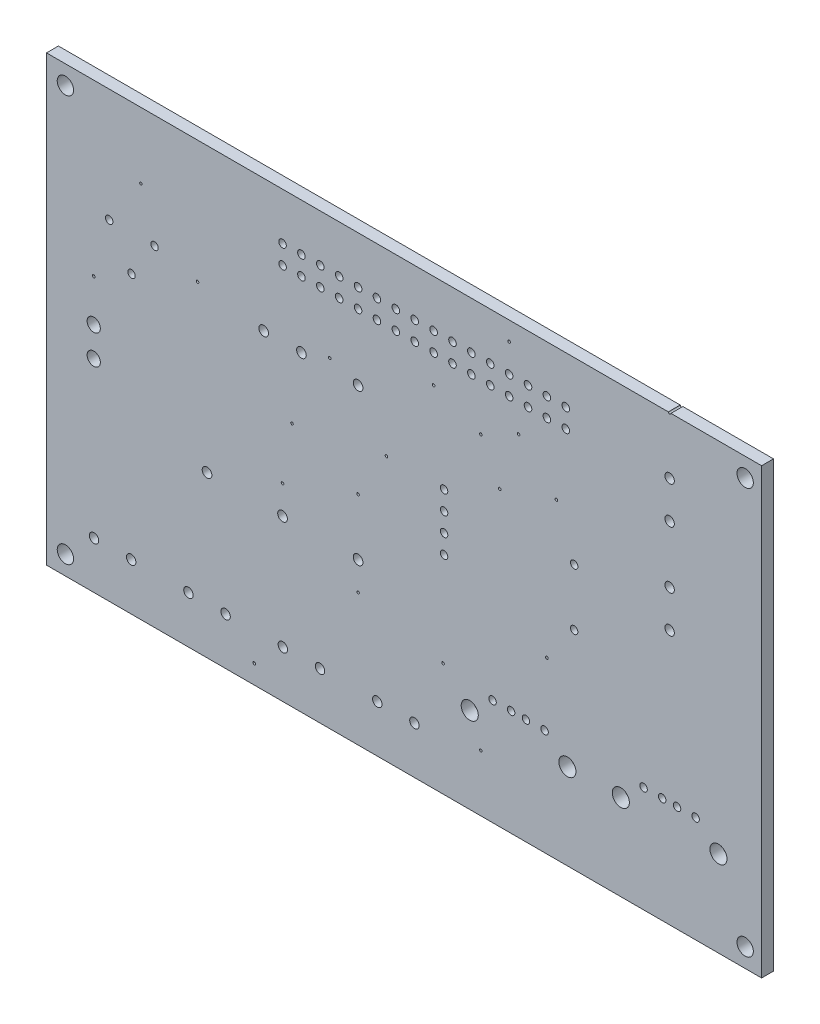
from build123d import *

# Parameters (mm, degrees)
SKETCH1_W           = 96.19
SKETCH1_H           = 59.68
BOARD_OUTLINE_DEPTH = 1.6
SKETCH2_R           = 1.1
SKETCH2_R_2         = 1.15
SKETCH2_R_3         = 0.175
NPTH_DEPTH          = 2.6
SKETCH3_R           = 0.5
SKETCH3_R_2         = 0.89
SKETCH3_R_3         = 0.635
SKETCH3_R_4         = 0.51
SKETCH3_R_5         = 0.65
PTH_DEPTH           = 2.6


with BuildPart() as part:
    # Sketch1 → Board_Outline (new body)
    with BuildSketch(Plane.XY):
        with Locations((51.905, 41.27)):
            Rectangle(SKETCH1_W, SKETCH1_H)
    extrude(amount=BOARD_OUTLINE_DEPTH)

    # Sketch2 → NPTH (cut, through all)
    with BuildSketch(Plane.XY):
        with Locations((6.35, 13.97)):
            Circle(SKETCH2_R)
        with Locations((6.35, 68.58)):
            Circle(SKETCH2_R)
        with Locations((97.79, 68.58)):
            Circle(SKETCH2_R)
        with Locations((97.79, 13.97)):
            Circle(SKETCH2_R)
        with Locations((81.06, 22.9799)):
            Circle(SKETCH2_R_2)
        with Locations((94.2, 22.9799)):
            Circle(SKETCH2_R_2)
        with Locations((60.74, 22.9799)):
            Circle(SKETCH2_R_2)
        with Locations((73.88, 22.9799)):
            Circle(SKETCH2_R_2)
        with Locations((62.23, 55.88)):
            Circle(SKETCH2_R_3)
        with Locations((71.12, 34.29)):
            Circle(SKETCH2_R_3)
        with Locations((36.83, 44.45)):
            Circle(SKETCH2_R_3)
        with Locations((41.91, 54.61)):
            Circle(SKETCH2_R_3)
        with Locations((45.72, 29.21)):
            Circle(SKETCH2_R_3)
        with Locations((62.23, 19.05)):
            Circle(SKETCH2_R_3)
        with Locations((31.75, 13.97)):
            Circle(SKETCH2_R_3)
        with Locations((55.88, 58.42)):
            Circle(SKETCH2_R_3)
        with Locations((16.51, 62.23)):
            Circle(SKETCH2_R_3)
        with Locations((24.13, 54.61)):
            Circle(SKETCH2_R_3)
        with Locations((45.72, 40.64)):
            Circle(SKETCH2_R_3)
        with Locations((49.53, 46.99)):
            Circle(SKETCH2_R_3)
        with Locations((57.15, 26.67)):
            Circle(SKETCH2_R_3)
        with Locations((10.16, 48.26)):
            Circle(SKETCH2_R_3)
        with Locations((66.04, 68.58)):
            Circle(SKETCH2_R_3)
        with Locations((87.63, 71.12)):
            Circle(SKETCH2_R_3)
        with Locations((72.39, 53.34)):
            Circle(SKETCH2_R_3)
        with Locations((67.31, 58.42)):
            Circle(SKETCH2_R_3)
        with Locations((64.77, 50.8)):
            Circle(SKETCH2_R_3)
        with Locations((35.56, 36.83)):
            Circle(SKETCH2_R_3)
    extrude(amount=NPTH_DEPTH, mode=Mode.SUBTRACT)

    # Sketch3 → PTH (cut, through all)
    with BuildSketch(Plane.XY):
        with Locations((18.34, 55.88)):
            Circle(SKETCH3_R)
        with Locations((15.24, 51.08)):
            Circle(SKETCH3_R)
        with Locations((12.24, 55.88)):
            Circle(SKETCH3_R)
        with Locations((10.16, 38.66)):
            Circle(SKETCH3_R_2)
        with Locations((10.16, 42.62)):
            Circle(SKETCH3_R_2)
        with Locations((87.63, 58.46)):
            Circle(SKETCH3_R_3)
        with Locations((87.63, 63.46)):
            Circle(SKETCH3_R_3)
        with Locations((57.29, 46.99)):
            Circle(SKETCH3_R)
        with Locations((57.29, 44.45)):
            Circle(SKETCH3_R)
        with Locations((57.29, 41.91)):
            Circle(SKETCH3_R)
        with Locations((57.29, 39.37)):
            Circle(SKETCH3_R)
        with Locations((74.79, 39.37)):
            Circle(SKETCH3_R)
        with Locations((74.79, 46.99)):
            Circle(SKETCH3_R)
        with Locations((87.63, 45.76)):
            Circle(SKETCH3_R_3)
        with Locations((87.63, 50.76)):
            Circle(SKETCH3_R_3)
        with Locations((35.56, 64.77)):
            Circle(SKETCH3_R_4)
        with Locations((35.56, 62.23)):
            Circle(SKETCH3_R_4)
        with Locations((38.1, 64.77)):
            Circle(SKETCH3_R_4)
        with Locations((38.1, 62.23)):
            Circle(SKETCH3_R_4)
        with Locations((40.64, 64.77)):
            Circle(SKETCH3_R_4)
        with Locations((40.64, 62.23)):
            Circle(SKETCH3_R_4)
        with Locations((43.18, 64.77)):
            Circle(SKETCH3_R_4)
        with Locations((43.18, 62.23)):
            Circle(SKETCH3_R_4)
        with Locations((45.72, 64.77)):
            Circle(SKETCH3_R_4)
        with Locations((45.72, 62.23)):
            Circle(SKETCH3_R_4)
        with Locations((48.26, 64.77)):
            Circle(SKETCH3_R_4)
        with Locations((48.26, 62.23)):
            Circle(SKETCH3_R_4)
        with Locations((50.8, 64.77)):
            Circle(SKETCH3_R_4)
        with Locations((50.8, 62.23)):
            Circle(SKETCH3_R_4)
        with Locations((53.34, 64.77)):
            Circle(SKETCH3_R_4)
        with Locations((53.34, 62.23)):
            Circle(SKETCH3_R_4)
        with Locations((55.88, 64.77)):
            Circle(SKETCH3_R_4)
        with Locations((55.88, 62.23)):
            Circle(SKETCH3_R_4)
        with Locations((58.42, 64.77)):
            Circle(SKETCH3_R_4)
        with Locations((58.42, 62.23)):
            Circle(SKETCH3_R_4)
        with Locations((60.96, 64.77)):
            Circle(SKETCH3_R_4)
        with Locations((60.96, 62.23)):
            Circle(SKETCH3_R_4)
        with Locations((63.5, 64.77)):
            Circle(SKETCH3_R_4)
        with Locations((63.5, 62.23)):
            Circle(SKETCH3_R_4)
        with Locations((66.04, 64.77)):
            Circle(SKETCH3_R_4)
        with Locations((66.04, 62.23)):
            Circle(SKETCH3_R_4)
        with Locations((68.58, 64.77)):
            Circle(SKETCH3_R_4)
        with Locations((68.58, 62.23)):
            Circle(SKETCH3_R_4)
        with Locations((71.12, 64.77)):
            Circle(SKETCH3_R_4)
        with Locations((71.12, 62.23)):
            Circle(SKETCH3_R_4)
        with Locations((73.66, 64.77)):
            Circle(SKETCH3_R_4)
        with Locations((73.66, 62.23)):
            Circle(SKETCH3_R_4)
        with Locations((40.6, 17.78)):
            Circle(SKETCH3_R_3)
        with Locations((35.6, 17.78)):
            Circle(SKETCH3_R_3)
        with Locations((15.2, 17.78)):
            Circle(SKETCH3_R_3)
        with Locations((10.2, 17.78)):
            Circle(SKETCH3_R_3)
        with Locations((27.9, 17.78)):
            Circle(SKETCH3_R_3)
        with Locations((22.9, 17.78)):
            Circle(SKETCH3_R_3)
        with Locations((53.3, 17.78)):
            Circle(SKETCH3_R_3)
        with Locations((48.3, 17.78)):
            Circle(SKETCH3_R_3)
        with Locations((33.02, 53.34)):
            Circle(SKETCH3_R_5)
        with Locations((25.4, 33.02)):
            Circle(SKETCH3_R_5)
        with Locations((38.1, 53.34)):
            Circle(SKETCH3_R_5)
        with Locations((45.72, 33.02)):
            Circle(SKETCH3_R_5)
        with Locations((45.72, 53.34)):
            Circle(SKETCH3_R_5)
        with Locations((35.56, 33.02)):
            Circle(SKETCH3_R_5)
        with Locations((84.13, 25.69)):
            Circle(SKETCH3_R)
        with Locations((86.63, 25.69)):
            Circle(SKETCH3_R)
        with Locations((88.63, 25.69)):
            Circle(SKETCH3_R)
        with Locations((91.13, 25.69)):
            Circle(SKETCH3_R)
        with Locations((63.81, 25.69)):
            Circle(SKETCH3_R)
        with Locations((66.31, 25.69)):
            Circle(SKETCH3_R)
        with Locations((68.31, 25.69)):
            Circle(SKETCH3_R)
        with Locations((70.81, 25.69)):
            Circle(SKETCH3_R)
    extrude(amount=PTH_DEPTH, mode=Mode.SUBTRACT)


solid = part.part
